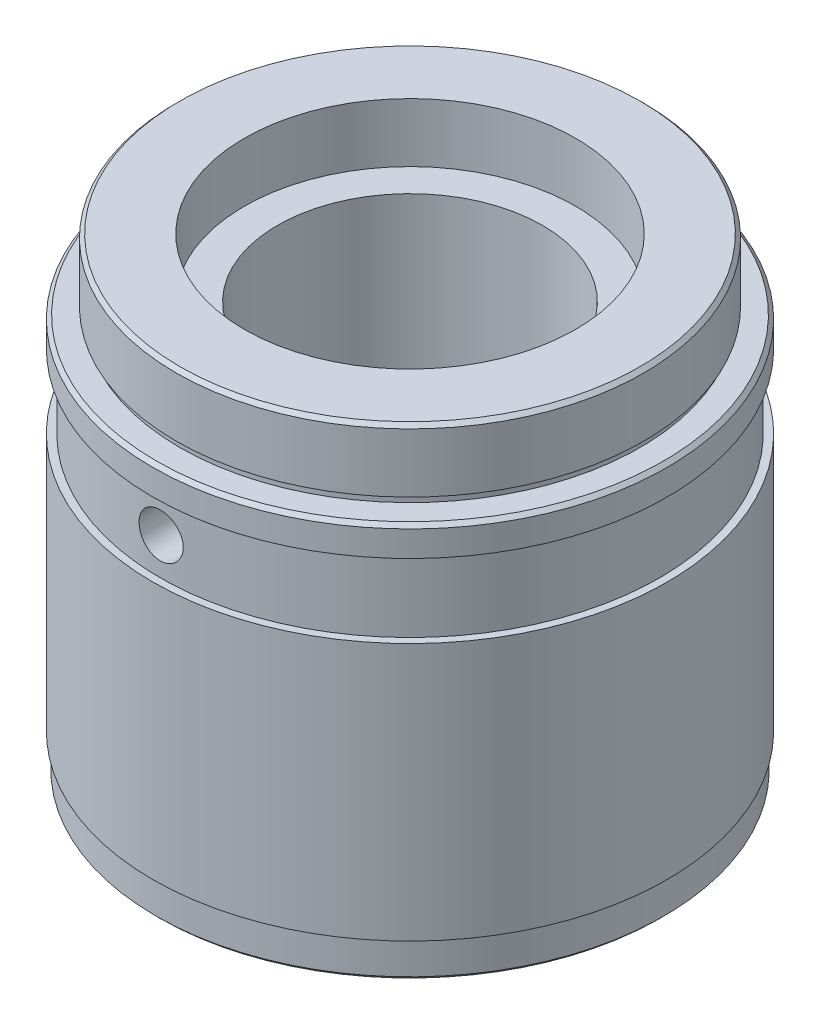
from build123d import *

# Parameters (mm, degrees)
SKETCH1_R                      = 34.925
MAIN_BODY_DEPTH                = 63.5
SKETCH2_OUTSIDE_W              = 95.336
SKETCH2_OUTSIDE_H              = 95.336
SKETCH2_OUTSIDE_R              = 34.5
BOTTOM_STEP_DEPTH              = 5
SKETCH3_OUTSIDE_W              = 95.336
SKETCH3_OUTSIDE_H              = 95.336
SKETCH3_OUTSIDE_R              = 31.75
TOP_DIAMETER_DEPTH             = 9.52
SKETCH4_OUTSIDE_W              = 95.336
SKETCH4_OUTSIDE_H              = 95.336
SKETCH4_OUTSIDE_R              = 31.25
CUT_EXTRUDE3_DEPTH             = 1
SKETCH5_R                      = 22.5
INSERT_BORE_DEPTH              = 8
SKETCH6_R                      = 18
CUT_EXTRUDE5_DEPTH             = 64.5
SKETCH7_R                      = 21
CUT_EXTRUDE6_DEPTH             = 5
BOTTOM_EDGE_CHAMFER_SIZE2      = 0.499999887
BOTTOM_EDGE_CHAMFER_SIZE       = 0.5
TOP_FACE_CHAMFER_SIZE2         = 0.499999887
TOP_FACE_CHAMFER_SIZE          = 0.5
BODY_TO_TOP_FACE_CHAMFER_SIZE2 = 0.499999887
BODY_TO_TOP_FACE_CHAMFER_SIZE  = 0.5
SKETCH8_W                      = 1
SKETCH8_H                      = 10
SKETCH9_R                      = 3
OIL_HOLE_DEPTH                 = 35.925


with BuildPart() as part:
    # Sketch1 → Main Body (new body)
    with BuildSketch(Plane(origin=(0, 0, 0), x_dir=(1, 0, 0), z_dir=(0, 1, 0))):
        Circle(SKETCH1_R)
    extrude(amount=MAIN_BODY_DEPTH)

    # Sketch2 outside → Bottom Step (cut)
    with BuildSketch(Plane.XZ):
        Rectangle(SKETCH2_OUTSIDE_W, SKETCH2_OUTSIDE_H)
        Circle(SKETCH2_OUTSIDE_R, mode=Mode.SUBTRACT)
    extrude(amount=-BOTTOM_STEP_DEPTH, mode=Mode.SUBTRACT)

    # Sketch3 outside → Top Diameter (cut)
    with BuildSketch(Plane(origin=(0, 63.5, 0), x_dir=(1, 0, 0), z_dir=(0, 1, 0))):
        Rectangle(SKETCH3_OUTSIDE_W, SKETCH3_OUTSIDE_H)
        Circle(SKETCH3_OUTSIDE_R, mode=Mode.SUBTRACT)
    extrude(amount=-TOP_DIAMETER_DEPTH, mode=Mode.SUBTRACT)

    # Sketch4 outside → Cut-Extrude3 (cut)
    with BuildSketch(Plane(origin=(0, 53.98, 0), x_dir=(1, 0, 0), z_dir=(0, 1, 0))):
        Rectangle(SKETCH4_OUTSIDE_W, SKETCH4_OUTSIDE_H)
        Circle(SKETCH4_OUTSIDE_R, mode=Mode.SUBTRACT)
    extrude(amount=CUT_EXTRUDE3_DEPTH, mode=Mode.SUBTRACT)

    # Sketch5 → Insert Bore (cut)
    with BuildSketch(Plane(origin=(0, 63.5, 0), x_dir=(1, 0, 0), z_dir=(0, 1, 0))):
        Circle(SKETCH5_R)
    extrude(amount=-INSERT_BORE_DEPTH, mode=Mode.SUBTRACT)

    # Sketch6 → Cut-Extrude5 (cut, through all)
    with BuildSketch(Plane.XZ):
        Circle(SKETCH6_R)
    extrude(amount=-CUT_EXTRUDE5_DEPTH, mode=Mode.SUBTRACT)

    # Sketch7 → Cut-Extrude6 (cut)
    with BuildSketch(Plane.XZ):
        Circle(SKETCH7_R)
    extrude(amount=-CUT_EXTRUDE6_DEPTH, mode=Mode.SUBTRACT)

    # Bottom Edge Chamfer
    bottom_edge_chamfer_edges = [part.edges().sort_by_distance(p)[0] for p in [
        (-34.5, 0, 0),
    ]]
    chamfer(bottom_edge_chamfer_edges, length=BOTTOM_EDGE_CHAMFER_SIZE, length2=BOTTOM_EDGE_CHAMFER_SIZE2)

    # Top Face Chamfer
    top_face_chamfer_edges = [part.edges().sort_by_distance(p)[0] for p in [
        (-31.75, 63.5, 0),
    ]]
    chamfer(top_face_chamfer_edges, length=TOP_FACE_CHAMFER_SIZE, length2=TOP_FACE_CHAMFER_SIZE2)

    # Body To Top Face Chamfer
    body_to_top_face_chamfer_edges = [part.edges().sort_by_distance(p)[0] for p in [
        (-34.925, 53.98, 0),
    ]]
    chamfer(body_to_top_face_chamfer_edges, length=BODY_TO_TOP_FACE_CHAMFER_SIZE, length2=BODY_TO_TOP_FACE_CHAMFER_SIZE2)

    # Sketch8 → Oil Groove (revolve, cut)
    with BuildSketch(Plane.XY):
        with Locations((34.425, 45)):
            Rectangle(SKETCH8_W, SKETCH8_H)
    revolve(axis=Axis((0, 0, 0), (0, 1, 0)), mode=Mode.SUBTRACT)

    # Sketch9 → Oil Hole (cut, through all)
    with BuildSketch(Plane.XY):
        with Locations((0, 45)):
            Circle(SKETCH9_R)
    extrude(amount=OIL_HOLE_DEPTH, mode=Mode.SUBTRACT)


solid = part.part
